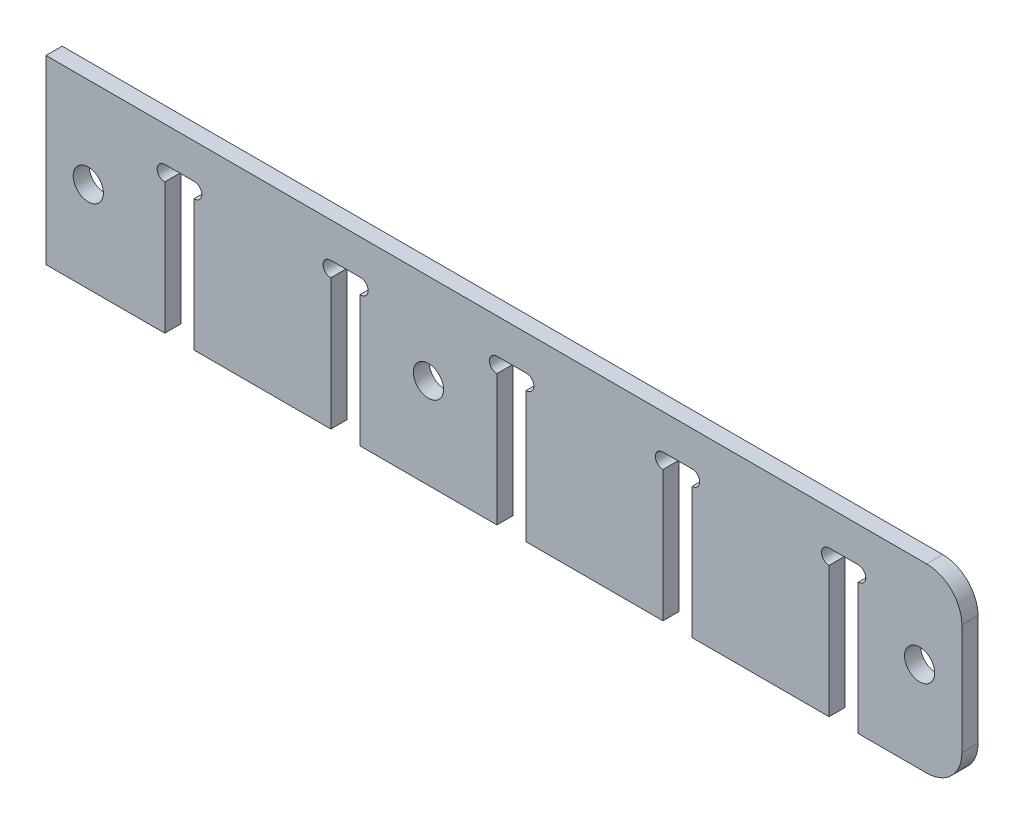
from build123d import *

# Parameters (mm, degrees)
SZKIC1_W                    = 91
SZKIC1_H                    = 18
DODANIE_WYCI_GNI_CIE1_DEPTH = 1.6
ZAOKR_GLENIE2_R             = 3.5
SZKIC5_W                    = 2.9
SZKIC5_H                    = 14.52
WYTNIJ_WYCI_GNI_CIE2_DEPTH  = 1.6
SZKIC7_R                    = 1.5
WYTNIJ_WYCI_GNI_CIE3_DEPTH  = 1.6
SZKIC10_R                   = 1.5
WYTNIJ_WYCI_GNI_CIE4_DEPTH  = 1.6
SZKIC11_R                   = 0.75
SZKIC11_R_2                 = 0.750301754
SZKIC11_R_3                 = 0.752070273
SZKIC11_R_4                 = 0.7503443
SZKIC11_R_5                 = 0.750020646
WYTNIJ_WYCI_GNI_CIE5_DEPTH  = 1.6


with BuildPart() as part:
    # Szkic1 → Dodanie-wyciągnięcie1 (new body)
    with BuildSketch(Plane.XY):
        with Locations((14.994318182, 16.981534091)):
            Rectangle(SZKIC1_W, SZKIC1_H)
    extrude(amount=DODANIE_WYCI_GNI_CIE1_DEPTH)

    # Zaokrąglenie2
    zaokr_glenie2_edges = [part.edges().sort_by_distance(p)[0] for p in [
        (60.494318182, 25.981534091, 0.8),
        (60.494318182, 7.981534091, 0.8),
    ]]
    fillet(zaokr_glenie2_edges, radius=ZAOKR_GLENIE2_R)

    # Szkic5 → Wytnij-wyciągnięcie2 (cut)
    with BuildSketch(Plane.XY.offset(1.6)):
        with Locations((-17.255681818, 15.241534091)):
            Rectangle(SZKIC5_W, SZKIC5_H)
        with Locations((-0.755681818, 15.241534091)):
            Rectangle(SZKIC5_W, SZKIC5_H)
        with Locations((15.744318182, 15.241534091)):
            Rectangle(SZKIC5_W, SZKIC5_H)
        with Locations((32.244318182, 15.241534091)):
            Rectangle(SZKIC5_W, SZKIC5_H)
        with Locations((48.744318182, 15.241534091)):
            Rectangle(SZKIC5_W, SZKIC5_H)
    extrude(amount=-WYTNIJ_WYCI_GNI_CIE2_DEPTH, mode=Mode.SUBTRACT)

    # Szkic7 → Wytnij-wyciągnięcie3 (cut)
    with BuildSketch(Plane.XY.offset(1.6)):
        with Locations((-26.305681818, 16.981534091)):
            Circle(SZKIC7_R)
        with Locations((56.294318182, 16.981534091)):
            Circle(SZKIC7_R)
    extrude(amount=-WYTNIJ_WYCI_GNI_CIE3_DEPTH, mode=Mode.SUBTRACT)

    # Szkic10 → Wytnij-wyciągnięcie4 (cut)
    with BuildSketch(Plane.XY.offset(1.6)):
        with Locations((7.494318182, 16.981534091)):
            Circle(SZKIC10_R)
    extrude(amount=-WYTNIJ_WYCI_GNI_CIE4_DEPTH, mode=Mode.SUBTRACT)

    # Szkic11 → Wytnij-wyciągnięcie5 (cut)
    with BuildSketch(Plane(origin=(0, 0, 0), x_dir=(-1, 0, 0), z_dir=(0, 0, -1))):
        with Locations((18.705681818, 21.751534091)):
            Circle(SZKIC11_R)
        with Locations((15.773526009, 21.751534091)):
            Circle(SZKIC11_R)
        with Locations((2.226959067, 21.751534091)):
            Circle(SZKIC11_R_2)
        with Locations((-0.75008283, 21.751534091)):
            Circle(SZKIC11_R_3)
        with Locations((-14.294318182, 21.751534091)):
            Circle(SZKIC11_R)
        with Locations((-17.217046338, 21.751534091)):
            Circle(SZKIC11_R_4)
        with Locations((-30.788753193, 21.751534091)):
            Circle(SZKIC11_R_5)
        with Locations((-33.694318182, 21.751534091)):
            Circle(SZKIC11_R)
        with Locations((-47.294318182, 21.751534091)):
            Circle(SZKIC11_R)
        with Locations((-50.194318182, 21.751534091)):
            Circle(SZKIC11_R)
    extrude(amount=-WYTNIJ_WYCI_GNI_CIE5_DEPTH, mode=Mode.SUBTRACT)


solid = part.part
